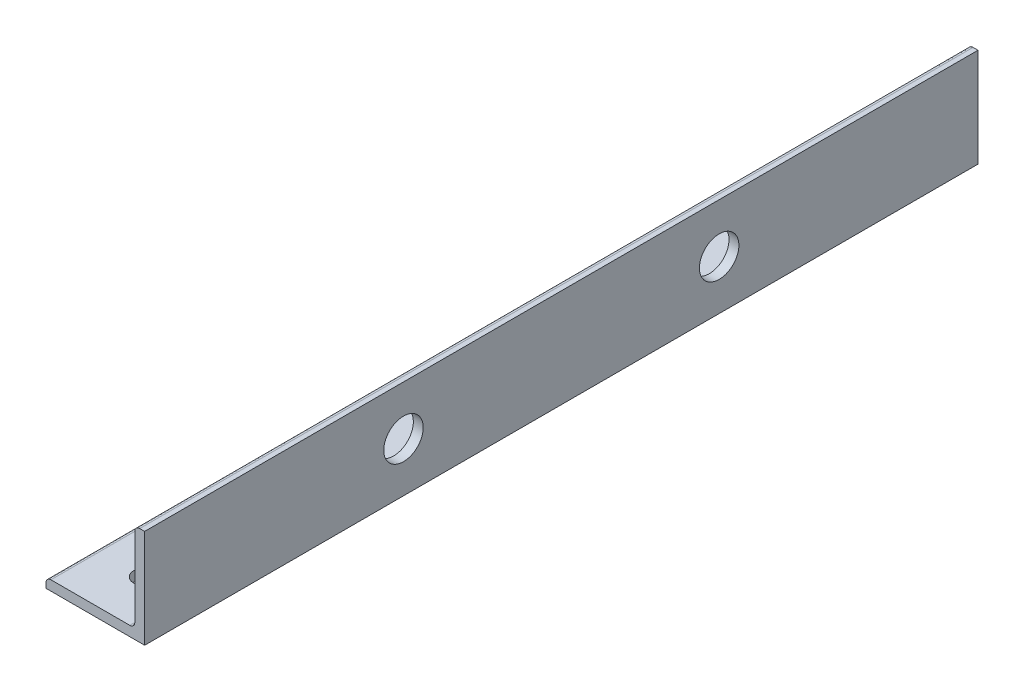
from build123d import *

# Parameters (mm, degrees)
BOSS_EXTRUDE1_DEPTH = 67.056
SKETCH3_R           = 3.175
CUT_EXTRUDE1_DEPTH  = 16.875
SKETCH4_R           = 1.7500092
CUT_EXTRUDE2_DEPTH  = 16.875


with BuildPart() as part:
    # Sketch2 → Boss-Extrude1 (new body, symmetric)
    with BuildSketch(Plane.XY):
        with BuildLine():
            Line((-7.9375, 0), (7.9375, 0))
            Line((7.9375, 0), (7.9375, 15.875))
            Line((7.9375, 15.875), (7.14375, 15.875))
            ThreePointArc((7.14375, 15.875), (6.582483992, 15.642516008), (6.35, 15.08125))
            Line((6.35, 15.08125), (6.35, 2.38125))
            ThreePointArc((6.35, 2.38125), (6.117516008, 1.819983992), (5.55625, 1.5875))
            Line((5.55625, 1.5875), (-7.14375, 1.5875))
            ThreePointArc((-7.14375, 1.5875), (-7.705016008, 1.355016008), (-7.9375, 0.79375))
            Line((-7.9375, 0.79375), (-7.9375, 0))
        make_face()
    extrude(amount=BOSS_EXTRUDE1_DEPTH, both=True)

    # Sketch3 → Cut-Extrude1 (cut, through all)
    with BuildSketch(Plane(origin=(7.9375, 0, 0), x_dir=(0, 0, -1), z_dir=(1, 0, 0))):
        with Locations((-25.4, 7.9375)):
            Circle(SKETCH3_R)
        with Locations((25.4, 7.9375)):
            Circle(SKETCH3_R)
    extrude(amount=-CUT_EXTRUDE1_DEPTH, mode=Mode.SUBTRACT)

    # Sketch4 → Cut-Extrude2 (cut, through all)
    with BuildSketch(Plane.XZ):
        with Locations((0, -59.1185)):
            Circle(SKETCH4_R)
        with Locations((0, 59.1185)):
            Circle(SKETCH4_R)
    extrude(amount=-CUT_EXTRUDE2_DEPTH, mode=Mode.SUBTRACT)


solid = part.part
